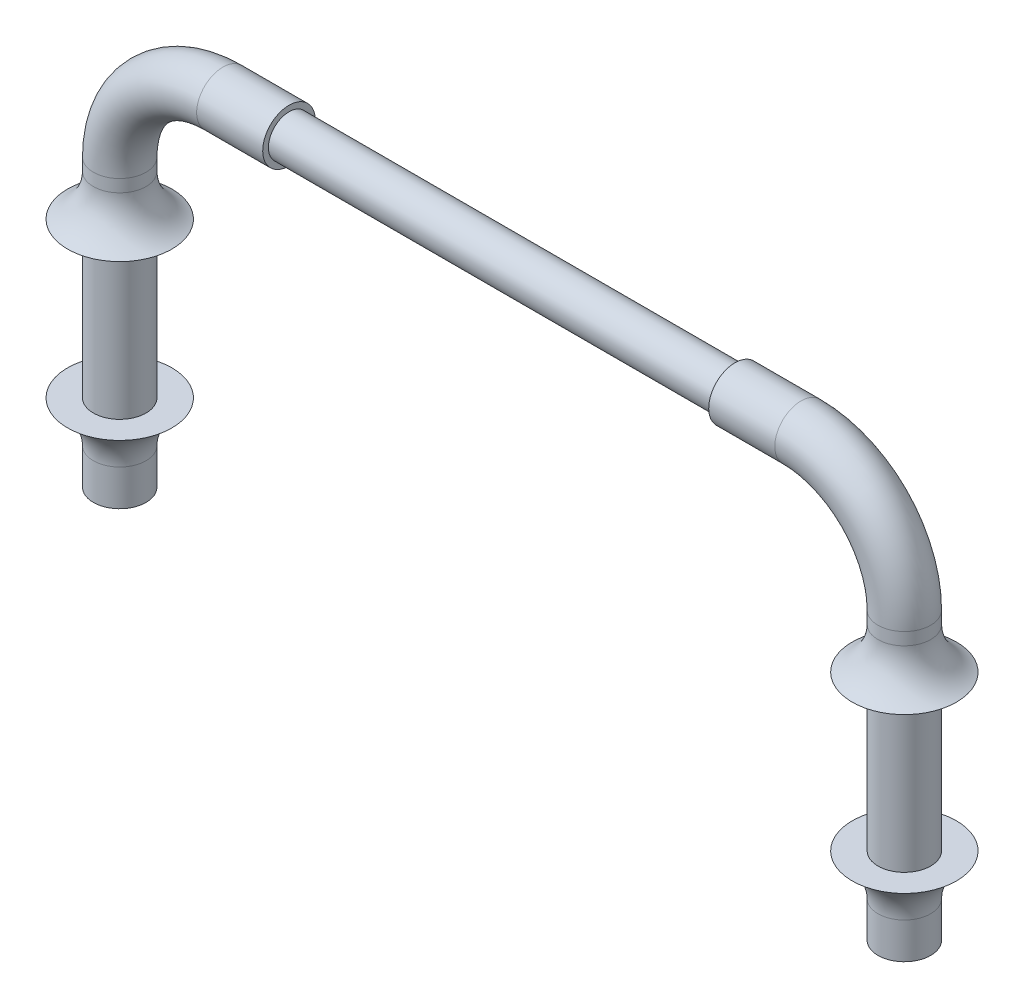
from build123d import *

# Parameters (mm, degrees)
SKETCH1_R      = 0.255
EXTRUDE1_DEPTH = 2
SKETCH2_R      = 0.255
EXTRUDE2_DEPTH = 0.77
SKETCH3_R      = 0.255
REVOLVE1_ANGLE = 90
SKETCH4_R      = 0.255
EXTRUDE4_DEPTH = 0.64
SKETCH6_R      = 0.2
EXTRUDE5_DEPTH = 4.32
SKETCH7_R      = 0.255
EXTRUDE6_DEPTH = 0.64
SKETCH8_R      = 0.255
REVOLVE3_ANGLE = 90
SKETCH9_R      = 0.255
EXTRUDE7_DEPTH = 2.77


with BuildPart() as part:
    # Sketch1 → Extrude1 (new body)
    with BuildSketch(Plane(origin=(0, 0, 0), x_dir=(1, 0, 0), z_dir=(0, 1, 0))):
        with Locations(Location((0, 0, 0), (0, 0, 270))):  # turned: the seam where the file's is
            Circle(SKETCH1_R)
    extrude(amount=-EXTRUDE1_DEPTH)

    # Sketch2 → Extrude2 (add)
    with BuildSketch(Plane(origin=(0, 0, 0), x_dir=(1, 0, 0), z_dir=(0, 1, 0))):
        with Locations(Location((0, 0, 0), (0, 0, 270))):  # turned: the seam where the file's is
            Circle(SKETCH2_R)
    extrude(amount=EXTRUDE2_DEPTH)

    # Sketch3 → Revolve1 (revolve)
    with BuildSketch(Plane(origin=(0, 0.77, 0), x_dir=(1, 0, 0), z_dir=(0, 1, 0))):
        with Locations(Location((0, 0, 0), (0, 0, 270))):  # turned: the seam where the file's is
            Circle(SKETCH3_R)
    revolve(axis=Axis((1, 0.77, -0.255), (0, 0, -1)), revolution_arc=REVOLVE1_ANGLE)

    # Sketch4 → Extrude4 (add)
    with BuildSketch(Plane(origin=(1, 0, 0), x_dir=(0, 0, -1), z_dir=(1, 0, 0))):
        with Locations(Location((0, 1.77, 0), (0, 0, 90))):  # turned: the seam where the file's is
            Circle(SKETCH4_R)
    extrude(amount=EXTRUDE4_DEPTH)

    # Sketch6 → Extrude5 (add)
    with BuildSketch(Plane(origin=(1.64, 0, 0), x_dir=(0, 0, -1), z_dir=(1, 0, 0))):
        with Locations(Location((0, 1.77, 0), (0, 0, 90))):  # turned: the seam where the file's is
            Circle(SKETCH6_R)
    extrude(amount=EXTRUDE5_DEPTH)

    # Sketch7 → Extrude6 (add)
    with BuildSketch(Plane(origin=(5.96, 0, 0), x_dir=(0, 0, -1), z_dir=(1, 0, 0))):
        with Locations(Location((0, 1.77, 0), (0, 0, 90))):  # turned: the seam where the file's is
            Circle(SKETCH7_R)
    extrude(amount=EXTRUDE6_DEPTH)

    # Sketch8 → Revolve3 (revolve)
    with BuildSketch(Plane(origin=(6.6, 0, 0), x_dir=(0, 0, -1), z_dir=(1, 0, 0))):
        with Locations(Location((0, 1.77, 0), (0, 0, 90))):  # turned: the seam where the file's is
            Circle(SKETCH8_R)
    revolve(axis=Axis((6.6, 0.77, 0.255), (0, 0, -1)), revolution_arc=REVOLVE3_ANGLE)

    # Sketch9 → Extrude7 (add)
    with BuildSketch(Plane.XZ.offset(-0.77)):
        with Locations(Location((7.6, 0, 0), (0, 0, 90))):  # turned: the seam where the file's is
            Circle(SKETCH9_R)
    extrude(amount=EXTRUDE7_DEPTH)

    # Sketch10 → Revolve4 (revolve)
    with BuildSketch(Plane.XY, mode=Mode.PRIVATE) as revolve4_sk:
        with BuildLine():
            Line((-0.255, 0.25), (-0.255, 0.65))
            ThreePointArc((-0.255, 0.65), (-0.322640755, 0.414150472), (-0.505, 0.25))
            Line((-0.505, 0.25), (-0.255, 0.25))
        make_face()
        with BuildLine():
            Line((-0.255, -1.25), (-0.505, -1.25))
            ThreePointArc((-0.505, -1.25), (-0.322640755, -1.414150472), (-0.255, -1.65))
            Line((-0.255, -1.65), (-0.255, -1.25))
        make_face()
    revolve(revolve4_sk.sketch.rotate(Axis((0, -2, 0), (0, 1, 0)), 270), axis=Axis((0, -2, 0), (0, 1, 0)))  # turned: the seam where the file's is

    # Sketch11 → Revolve5 (revolve)
    with BuildSketch(Plane.XY):
        with BuildLine():
            Line((7.855, 0.25), (8.105, 0.25))
            ThreePointArc((8.105, 0.25), (7.922640755, 0.414150472), (7.855, 0.65))
            Line((7.855, 0.65), (7.855, 0.25))
        make_face()
        with BuildLine():
            Line((7.855, -1.25), (8.105, -1.25))
            ThreePointArc((8.105, -1.25), (7.922640755, -1.414150472), (7.855, -1.65))
            Line((7.855, -1.65), (7.855, -1.25))
        make_face()
    revolve(axis=Axis((7.6, -2, 0), (0, 1, 0)))


solid = part.part
